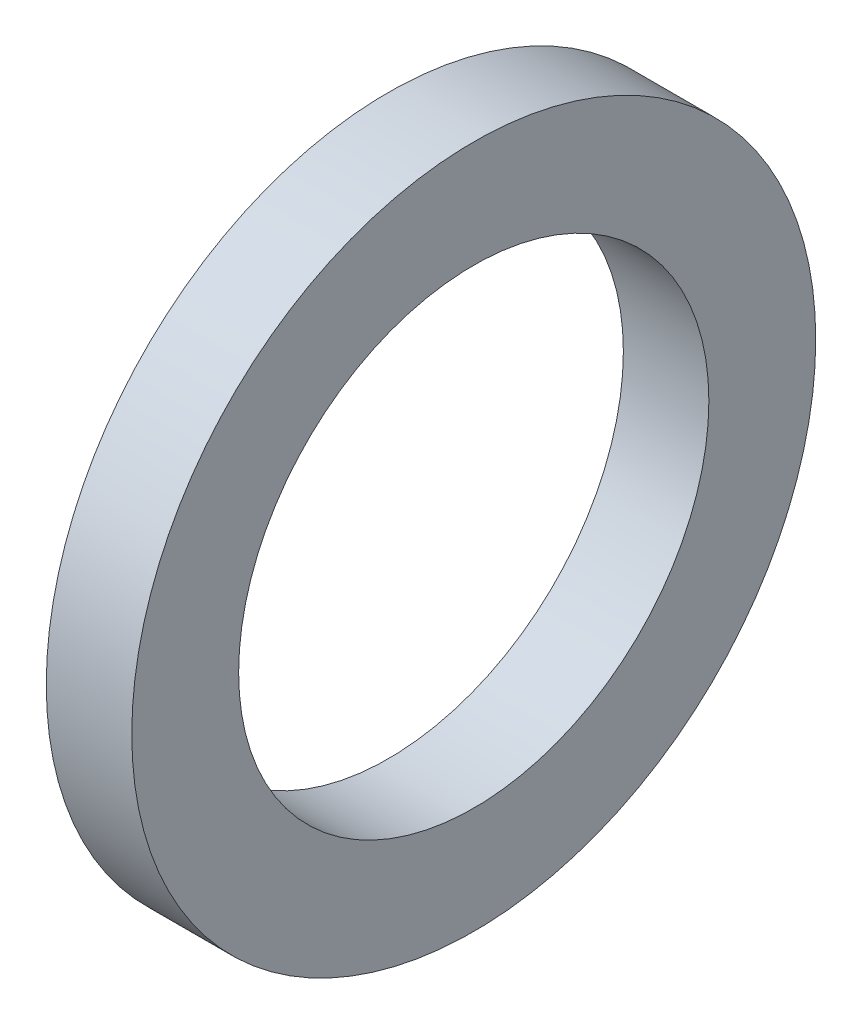
from build123d import *

# Parameters (mm, degrees)
SKETCH1_W = 20
SKETCH1_H = 25


with BuildPart() as part:
    # Sketch1 → Revolve1 (revolve)
    with BuildSketch(Plane.XY):
        with Locations((10, 12.5)):
            Rectangle(SKETCH1_W, SKETCH1_H)
    revolve(axis=Axis((-87.140343237, -55, 0), (1, 0, 0)))


solid = part.part
